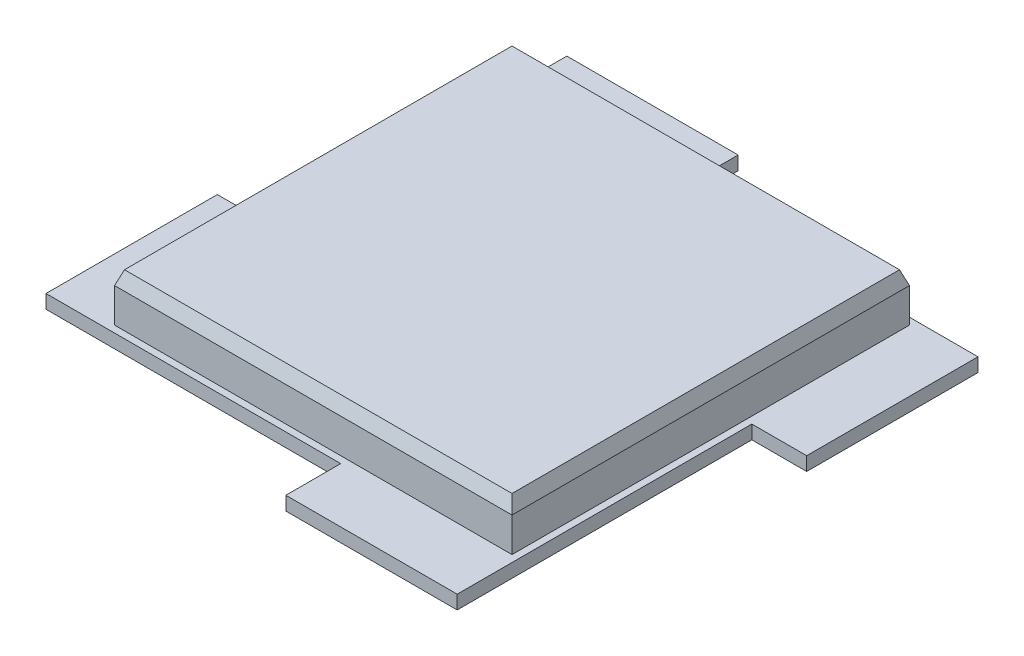
from build123d import *

# Parameters (mm, degrees)
BOSS_EXTRU_1_DEPTH = 2
ESQUISSE2_W        = 58
ESQUISSE2_H        = 58
BOSS_EXTRU_2_DEPTH = 5
BOSS_EXTRU_3_START = 5
ESQUISSE2_3_W      = 58
ESQUISSE2_3_H      = 58
BOSS_EXTRU_3_DEPTH = 2
BOSS_EXTRU_3_TAPER = 20


with BuildPart() as part:
    # Esquisse1 → Boss.-Extru.1 (new body)
    with BuildSketch(Plane(origin=(0, 0, 0), x_dir=(1, 0, 0), z_dir=(0, 1, 0))):
        Polygon((8, 33), (0, 33), (0, 8), (43, 8), (43, 0), (68, 0), (68, 43), (76, 43), (76, 68), (33, 68), (33, 76), (8, 76), align=None)
    extrude(amount=BOSS_EXTRU_1_DEPTH)

    # Esquisse2 → Boss.-Extru.2 (add)
    with BuildSketch(Plane(origin=(0, 2, 0), x_dir=(1, 0, 0), z_dir=(0, 1, 0))):
        with Locations((38, 38)):
            Rectangle(ESQUISSE2_W, ESQUISSE2_H)
    extrude(amount=BOSS_EXTRU_2_DEPTH)

    # Esquisse2_3 → Boss.-Extru.3 (add)
    with BuildSketch(Plane(origin=(0, 2, 0), x_dir=(1, 0, 0), z_dir=(0, 1, 0)).offset(BOSS_EXTRU_3_START)):
        with Locations((38, 38)):
            Rectangle(ESQUISSE2_3_W, ESQUISSE2_3_H)
    extrude(amount=BOSS_EXTRU_3_DEPTH, taper=BOSS_EXTRU_3_TAPER)


solid = part.part
